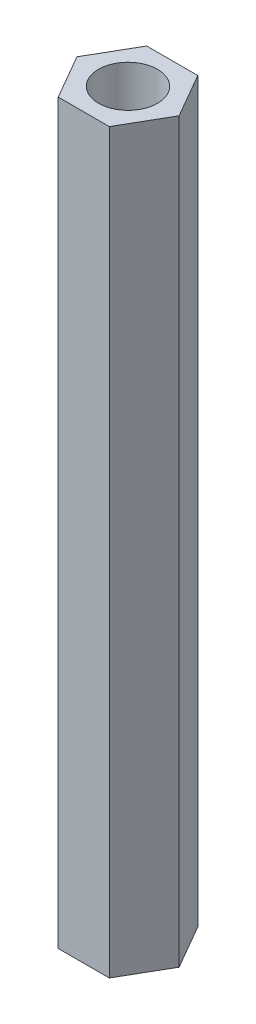
from build123d import *

# Parameters (mm, degrees)
SKETCH_1_R      = 2
EXTRUDE_1_DEPTH = 50


with BuildPart() as part:
    # 草图1 → 凸台-拉伸1 (new body)
    with BuildSketch(Plane(origin=(0, 0, 0), x_dir=(1, 0, 0), z_dir=(0, 1, 0))):
        Polygon((1.732050808, 3), (-1.732050808, 3), (-3.464101615, 0), (-1.732050808, -3), (1.732050808, -3), (3.464101615, 0), align=None)
        Circle(SKETCH_1_R, mode=Mode.SUBTRACT)
    extrude(amount=EXTRUDE_1_DEPTH)


solid = part.part
